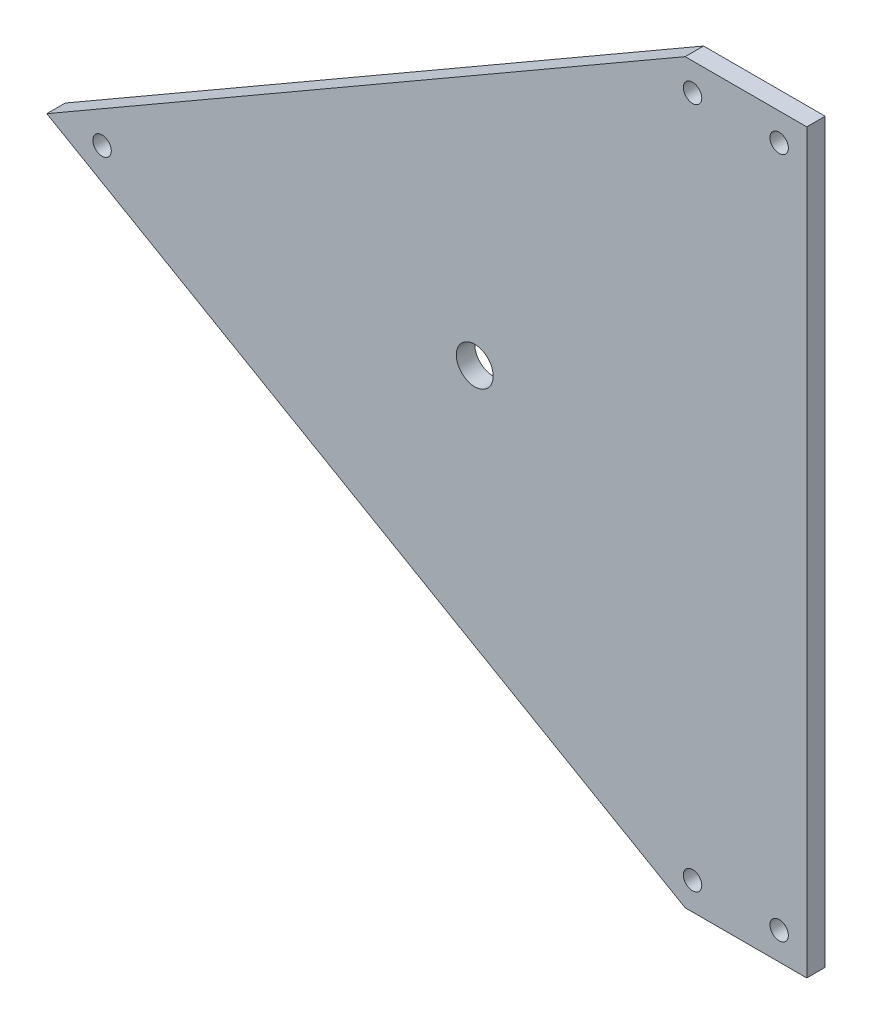
from build123d import *

# Parameters (mm, degrees)
SKETCH1_R           = 2.5
SKETCH1_R_2         = 5
BOSS_EXTRUDE1_DEPTH = 5


with BuildPart() as part:
    # Sketch1 → Boss-Extrude1 (new body)
    with BuildSketch(Plane.XY):
        Polygon((-30.5, 0), (-203.705080757, -100), (-30.5, -200), (2.5, -200), (2.5, 0), align=None)
        with Locations((-188.705080757, -100)):
            Circle(SKETCH1_R, mode=Mode.SUBTRACT)
        with Locations((-28.490381057, -7.5)):
            Circle(SKETCH1_R, mode=Mode.SUBTRACT)
        with Locations((-5, -7.5)):
            Circle(SKETCH1_R, mode=Mode.SUBTRACT)
        with Locations((-5, -192.5)):
            Circle(SKETCH1_R, mode=Mode.SUBTRACT)
        with Locations((-28.490381057, -192.5)):
            Circle(SKETCH1_R, mode=Mode.SUBTRACT)
        with Locations((-87.586729605, -101.122883886)):
            Circle(SKETCH1_R_2, mode=Mode.SUBTRACT)
    extrude(amount=BOSS_EXTRUDE1_DEPTH)


solid = part.part
